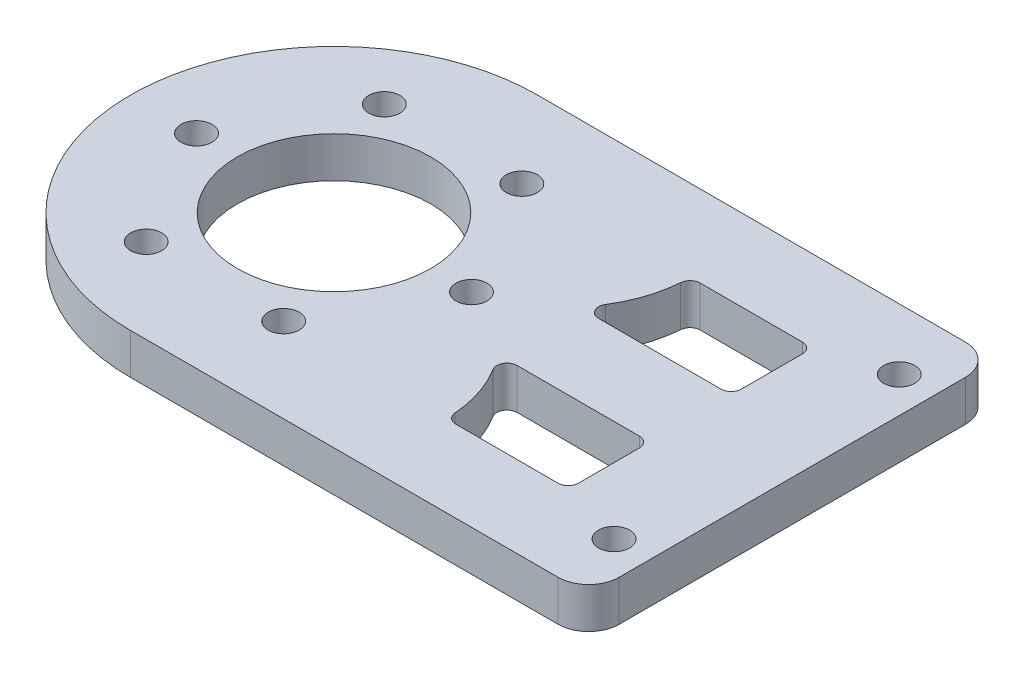
from build123d import *

# Parameters (mm, degrees)
EXTRUDE_1_DEPTH     = 4
SKETCH_3_R          = 1.525
CUT_EXTRUDE_3_DEPTH = 5
SKETCH_6_R          = 9.5
CUT_EXTRUDE_5_DEPTH = 5
FILLET_1_R          = 3
SKETCH_7_R          = 1.525
CUT_EXTRUDE_6_DEPTH = 10
CUT_EXTRUDE_7_DEPTH = 10
FILLET_2_R          = 1


with BuildPart() as part:
    # 草图1 → 凸台-拉伸1 (new body)
    with BuildSketch(Plane(origin=(0, 0, 0), x_dir=(1, 0, 0), z_dir=(0, 1, 0))):
        with BuildLine():
            ThreePointArc((-22.5, 20), (-42.5, 0), (-22.5, -20))
            Line((-22.5, -20), (-22.5, 20))
        make_face()
        with BuildLine():
            Line((-22.5, 20), (-22.5, -20))
            ThreePointArc((-22.5, -20), (-8.357864376, -14.142135624), (-2.5, 0))
            ThreePointArc((-2.5, 0), (-8.357864376, 14.142135624), (-22.5, 20))
        make_face()
        with BuildLine():
            ThreePointArc((-2.5, 0), (-8.357864376, -14.142135624), (-22.5, -20))
            Line((-22.5, -20), (22.5, -20))
            Line((22.5, -20), (22.5, 20))
            Line((22.5, 20), (-22.5, 20))
            ThreePointArc((-22.5, 20), (-8.357864376, 14.142135624), (-2.5, 0))
        make_face()
    extrude(amount=EXTRUDE_1_DEPTH)

    # 草图3 → 切除-拉伸3 (cut, through all)
    with BuildSketch(Plane(origin=(0, 0, 0), x_dir=(1, 0, 0), z_dir=(0, 1, 0))):
        with Locations((-36, 0)):
            Circle(SKETCH_3_R)
        with Locations((-29.25, 11.691342951)):
            Circle(SKETCH_3_R)
        with Locations((-15.75, 11.691342951)):
            Circle(SKETCH_3_R)
        with Locations((-9, 0)):
            Circle(SKETCH_3_R)
        with Locations((-15.75, -11.691342951)):
            Circle(SKETCH_3_R)
        with Locations((-29.25, -11.691342951)):
            Circle(SKETCH_3_R)
    extrude(amount=CUT_EXTRUDE_3_DEPTH, mode=Mode.SUBTRACT)

    # 草图6 → 切除-拉伸5 (cut, through all)
    with BuildSketch(Plane.XZ):
        with Locations((-22.5, 0)):
            Circle(SKETCH_6_R)
    extrude(amount=-CUT_EXTRUDE_5_DEPTH, mode=Mode.SUBTRACT)

    # 圆角1
    fillet_1_edges = [part.edges().sort_by_distance(p)[0] for p in [
        (22.5, 2, -20),
        (22.5, 2, 20),
    ]]
    fillet(fillet_1_edges, radius=FILLET_1_R)

    # 草图7 → 切除-拉伸6 (cut)
    with BuildSketch(Plane(origin=(0, 4, 0), x_dir=(1, 0, 0), z_dir=(0, 1, 0))):
        with Locations((19, -14)):
            Circle(SKETCH_7_R)
        with Locations((18.999999998, 13.999999998)):
            Circle(SKETCH_7_R)
    extrude(amount=-CUT_EXTRUDE_6_DEPTH, mode=Mode.SUBTRACT)

    # 草图8 → 切除-拉伸7 (cut)
    with BuildSketch(Plane.XZ):
        with BuildLine():
            Line((-2.5, 4), (12.5, 4))
            Line((12.5, 4), (12.5, 12))
            Line((12.5, 12), (0.5, 12))
            ThreePointArc((0.5, 12), (-0.274661673, 7.727998127), (-2.5, 4))
        make_face()
        with BuildLine():
            Line((12.5, -12), (0.5, -12))
            ThreePointArc((0.5, -12), (-0.274661673, -7.727998127), (-2.5, -4))
            Line((-2.5, -4), (12.5, -4))
            Line((12.5, -4), (12.5, -12))
        make_face()
    extrude(amount=-CUT_EXTRUDE_7_DEPTH, mode=Mode.SUBTRACT)

    # 圆角2
    fillet_2_edges = [part.edges().sort_by_distance(p)[0] for p in [
        (-2.5, 2, 4),
        (0.5, 2, 12),
        (12.5, 2, 12),
        (12.5, 2, 4),
        (0.5, 2, -12),
        (-2.5, 2, -4),
        (12.5, 2, -4),
        (12.5, 2, -12),
    ]]
    fillet(fillet_2_edges, radius=FILLET_2_R)


solid = part.part
